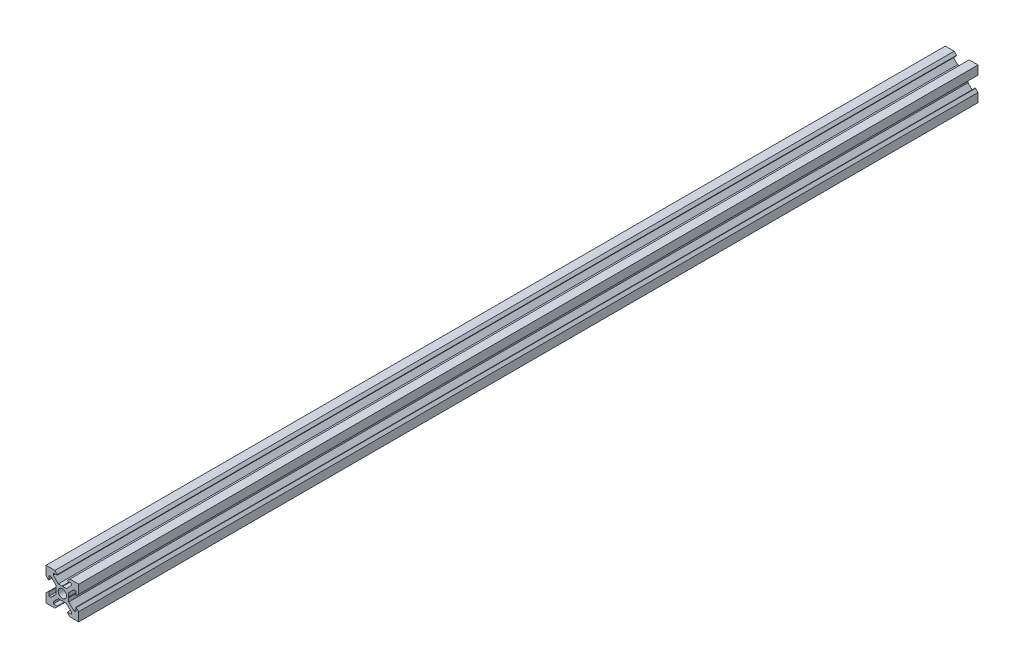
from build123d import *

# Parameters (mm, degrees)
SKETCH_1_R      = 2.55
EXTRUDE_1_DEPTH = 550


with BuildPart() as part:
    # Эскиз1 → Бобышка-Вытянуть1 (new body)
    with BuildSketch(Plane(origin=(0, 0, 0), x_dir=(-1, 0, 0), z_dir=(0, 0, -1))):
        Polygon((0, -3.7), (0.2, -3.9), (2.478143526, -3.9), (5.5, -7.00202244), (5.5, -8.2), (3.125, -8.2), (3.125, -8.506400721), (4.58, -10), (10, -10), (10, -4.58), (8.506400721, -3.125), (8.2, -3.125), (8.2, -5.5), (7.00202244, -5.5), (3.9, -2.478143526), (3.9, -0.2), (3.7, 0), (3.9, 0.2), (3.9, 2.478143526), (7.00202244, 5.5), (8.2, 5.5), (8.2, 3.125), (8.506400721, 3.125), (10, 4.58), (10, 10), (4.58, 10), (3.125, 8.506400721), (3.125, 8.2), (5.5, 8.2), (5.5, 7.00202244), (2.478143526, 3.9), (0.2, 3.9), (0, 3.7), (-0.2, 3.9), (-2.478143526, 3.9), (-5.5, 7.00202244), (-5.5, 8.2), (-3.125, 8.2), (-3.125, 8.506400721), (-4.58, 10), (-10, 10), (-10, 4.58), (-8.506400721, 3.125), (-8.2, 3.125), (-8.2, 5.5), (-7.00202244, 5.5), (-3.9, 2.478143526), (-3.9, 0.2), (-3.7, 0), (-3.9, -0.2), (-3.9, -2.478143526), (-7.00202244, -5.5), (-8.2, -5.5), (-8.2, -3.125), (-8.506400721, -3.125), (-10, -4.58), (-10, -10), (-4.58, -10), (-3.125, -8.506400721), (-3.125, -8.2), (-5.5, -8.2), (-5.5, -7.00202244), (-2.478143526, -3.9), (-0.2, -3.9), align=None)
        Circle(SKETCH_1_R, mode=Mode.SUBTRACT)
    extrude(amount=-EXTRUDE_1_DEPTH)


solid = part.part
